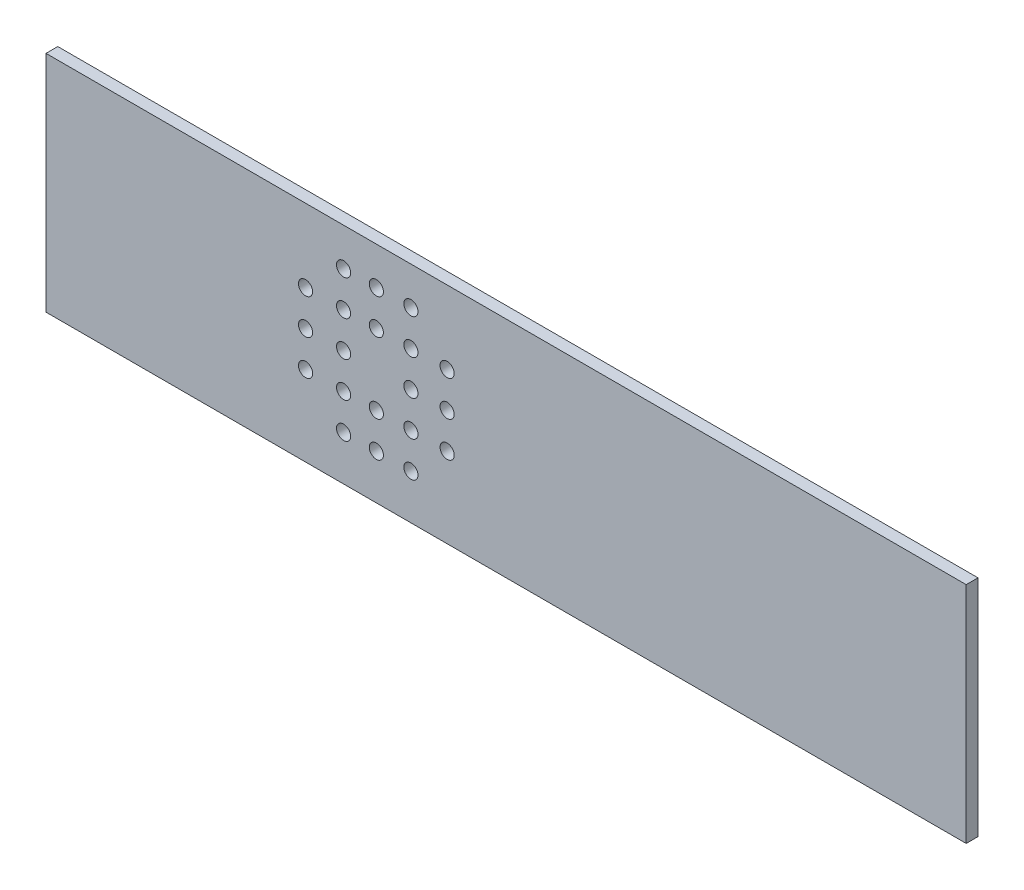
from build123d import *

# Parameters (mm, degrees)
CROQUIS1_W              = 390
CROQUIS1_H              = 95
CROQUIS1_R              = 3
SALIENTE_EXTRUIR1_DEPTH = 5


with BuildPart() as part:
    # Croquis1 → Saliente-Extruir1 (new body)
    with BuildSketch(Plane.XY):
        with Locations((177.18908942, -38.723014257)):
            Rectangle(CROQUIS1_W, CROQUIS1_H)
        with Locations((92.18908942, -37.240791093)):
            Circle(CROQUIS1_R, mode=Mode.SUBTRACT)
        with Locations((152.18908942, -37.240791093)):
            Circle(CROQUIS1_R, mode=Mode.SUBTRACT)
        with Locations((108.306752514, -37.240791093)):
            Circle(CROQUIS1_R, mode=Mode.SUBTRACT)
        with Locations((122.18908942, -7.240791093)):
            Circle(CROQUIS1_R, mode=Mode.SUBTRACT)
        with Locations((122.18908942, -67.240791093)):
            Circle(CROQUIS1_R, mode=Mode.SUBTRACT)
        with Locations((122.18908942, -52.240791093)):
            Circle(CROQUIS1_R, mode=Mode.SUBTRACT)
        with Locations((136.844623791, -37.240791093)):
            Circle(CROQUIS1_R, mode=Mode.SUBTRACT)
        with Locations((122.18908942, -22.240791093)):
            Circle(CROQUIS1_R, mode=Mode.SUBTRACT)
        with Locations((136.844623791, -52.240791093)):
            Circle(CROQUIS1_R, mode=Mode.SUBTRACT)
        with Locations((108.306752514, -52.240791093)):
            Circle(CROQUIS1_R, mode=Mode.SUBTRACT)
        with Locations((136.844623791, -22.240791093)):
            Circle(CROQUIS1_R, mode=Mode.SUBTRACT)
        with Locations((108.306752514, -22.240791093)):
            Circle(CROQUIS1_R, mode=Mode.SUBTRACT)
        with Locations((152.18908942, -22.240791093)):
            Circle(CROQUIS1_R, mode=Mode.SUBTRACT)
        with Locations((136.844623791, -7.240791093)):
            Circle(CROQUIS1_R, mode=Mode.SUBTRACT)
        with Locations((152.18908942, -52.240791093)):
            Circle(CROQUIS1_R, mode=Mode.SUBTRACT)
        with Locations((136.844623791, -67.240791093)):
            Circle(CROQUIS1_R, mode=Mode.SUBTRACT)
        with Locations((108.306752514, -67.240791093)):
            Circle(CROQUIS1_R, mode=Mode.SUBTRACT)
        with Locations((92.18908942, -52.240791093)):
            Circle(CROQUIS1_R, mode=Mode.SUBTRACT)
        with Locations((92.18908942, -22.240791093)):
            Circle(CROQUIS1_R, mode=Mode.SUBTRACT)
        with Locations((108.306752514, -7.240791093)):
            Circle(CROQUIS1_R, mode=Mode.SUBTRACT)
    extrude(amount=SALIENTE_EXTRUIR1_DEPTH)


solid = part.part
